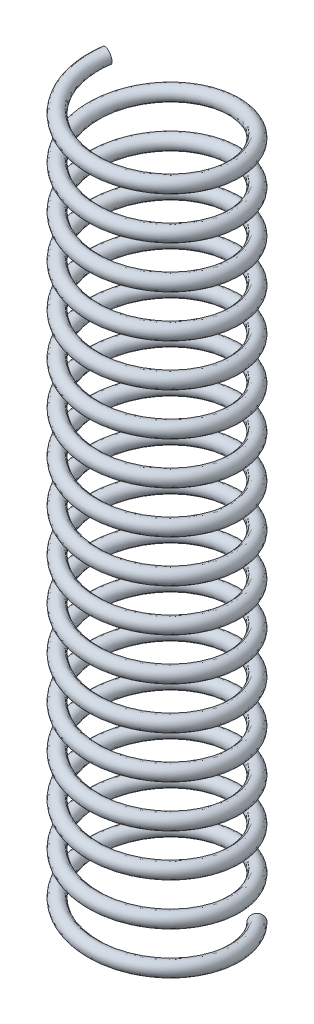
from build123d import *

# Parameters (mm, degrees)
SWEEP1_PITCH       = 3
SWEEP1_HEIGHT      = 50
SWEEP1_RADIUS      = 5
SWEEP1_START_ANGLE = 135
SWEEP1_PROFILE_R   = 0.5


with BuildPart() as part:
    # Sweep1: sweep along a helix
    with BuildLine() as sweep1_path:
        add(Helix(SWEEP1_PITCH, SWEEP1_HEIGHT, SWEEP1_RADIUS, center=(0, 0, 0), direction=(0, 1, 0), lefthand=True, mode=Mode.PRIVATE).rotate(Axis((0, 0, 0), (0, 1, 0)), SWEEP1_START_ANGLE))
    # Sweep1 profile (on start of the path) → Sweep1 (sweep)
    with BuildSketch(Plane(origin=(3.535533906, 0, -3.535533906), x_dir=(-0.707106781, 0, 0.707106781), z_dir=(0.703904644, 0.095060525, 0.703904644))):
        Circle(SWEEP1_PROFILE_R)
    sweep(path=sweep1_path.line, is_frenet=True)


solid = part.part
